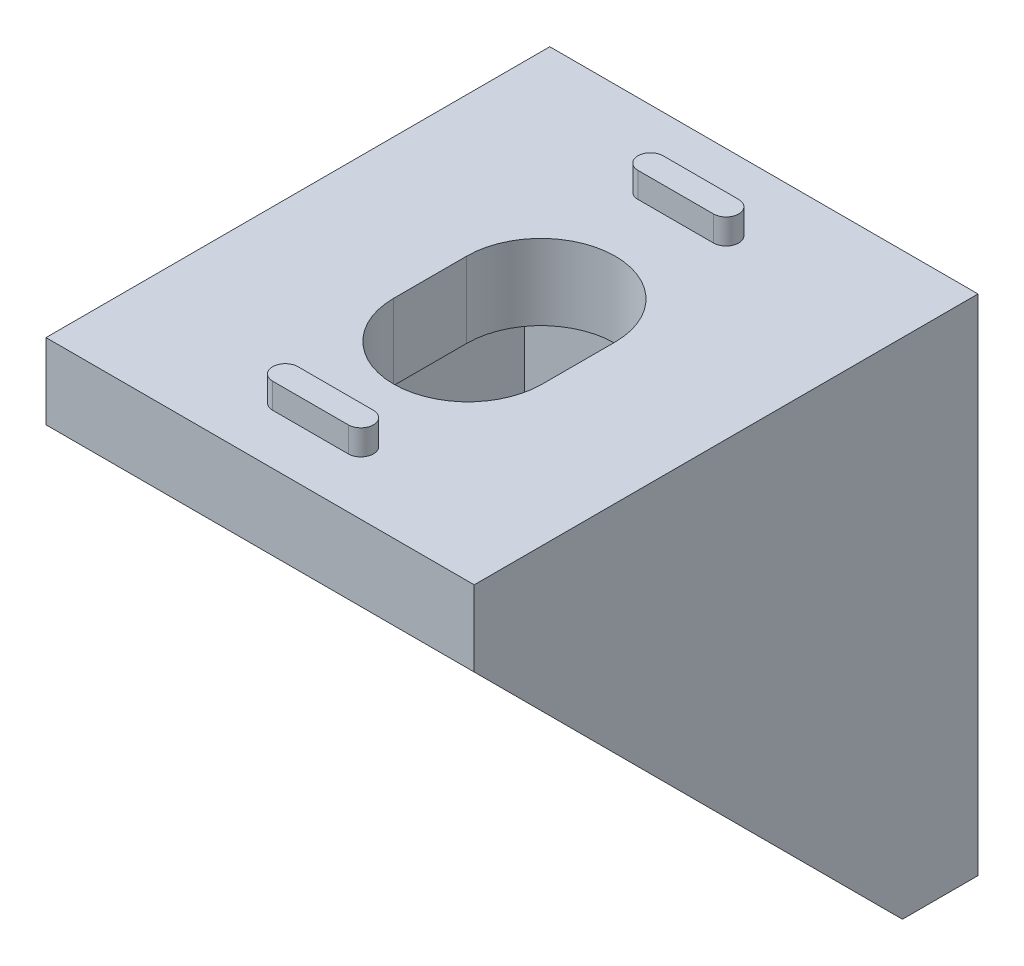
from build123d import *

# Parameters (mm, degrees)
SKETCH_1_W          = 17
SKETCH_1_H          = 20
EXTRUDE_1_DEPTH     = 3
SKETCH_2_W          = 17
SKETCH_2_H          = 3
EXTRUDE_2_DEPTH     = 17
EXTRUDE_3_DEPTH     = 2
EXTRUDE_4_DEPTH     = 2
EXTRUDE_5_DEPTH     = 1
EXTRUDE_6_DEPTH     = 1
CUT_EXTRUDE_3_DEPTH = 21
CUT_EXTRUDE_4_DEPTH = 21


with BuildPart() as part:
    # 草图1 → 凸台-拉伸1 (new body)
    with BuildSketch(Plane.XY):
        Rectangle(SKETCH_1_W, SKETCH_1_H)
    extrude(amount=EXTRUDE_1_DEPTH)

    # 草图2 → 凸台-拉伸2 (add)
    with BuildSketch(Plane.XY.offset(3)):
        with Locations((0, 8.5)):
            Rectangle(SKETCH_2_W, SKETCH_2_H)
    extrude(amount=EXTRUDE_2_DEPTH)

    # 草图3 → 凸台-拉伸3 (add)
    with BuildSketch(Plane.ZY.offset(8.5)):
        Polygon((20, 7), (3, -10), (3, 7), align=None)
    extrude(amount=-EXTRUDE_3_DEPTH)

    # 草图4 → 凸台-拉伸4 (add)
    with BuildSketch(Plane(origin=(8.5, 0, 0), x_dir=(0, 0, -1), z_dir=(1, 0, 0))):
        Polygon((-20, 7), (-3, -10), (-3, 7), align=None)
    extrude(amount=-EXTRUDE_4_DEPTH)

    # 草图5 → 凸台-拉伸5 (add)
    with BuildSketch(Plane(origin=(0, 10, 0), x_dir=(1, 0, 0), z_dir=(0, 1, 0))):
        with BuildLine():
            Line((-1.5, -2.5), (1.5, -2.5))
            ThreePointArc((1.5, -2.5), (2, -3), (1.5, -3.5))
            Line((1.5, -3.5), (-1.5, -3.5))
            ThreePointArc((-1.5, -3.5), (-2, -3), (-1.5, -2.5))
        make_face()
        with BuildLine():
            Line((-1.5, -17), (1.5, -17))
            ThreePointArc((1.5, -17), (2, -17.5), (1.5, -18))
            Line((1.5, -18), (-1.5, -18))
            ThreePointArc((-1.5, -18), (-2, -17.5), (-1.5, -17))
        make_face()
    extrude(amount=EXTRUDE_5_DEPTH)

    # 草图6 → 凸台-拉伸6 (add)
    with BuildSketch(Plane(origin=(0, 0, 0), x_dir=(-1, 0, 0), z_dir=(0, 0, -1))):
        with BuildLine():
            Line((-1.5, 7.5), (1.5, 7.5))
            ThreePointArc((1.5, 7.5), (2, 7), (1.5, 6.5))
            Line((1.5, 6.5), (-1.5, 6.5))
            ThreePointArc((-1.5, 6.5), (-2, 7), (-1.5, 7.5))
        make_face()
        with BuildLine():
            Line((-1.5, -7), (1.5, -7))
            ThreePointArc((1.5, -7), (2, -7.5), (1.5, -8))
            Line((1.5, -8), (-1.5, -8))
            ThreePointArc((-1.5, -8), (-2, -7.5), (-1.5, -7))
        make_face()
    extrude(amount=EXTRUDE_6_DEPTH)

    # 草图7 → 切除-拉伸3 (cut, through all)
    with BuildSketch(Plane(origin=(0, 0, 0), x_dir=(-1, 0, 0), z_dir=(0, 0, -1))):
        with BuildLine():
            Line((2.95, 1.15), (2.95, -1.75))
            ThreePointArc((2.95, -1.75), (0, -4.7), (-2.95, -1.75))
            Line((-2.95, -1.75), (-2.95, 1.15))
            ThreePointArc((-2.95, 1.15), (0, 4.1), (2.95, 1.15))
        make_face()
    extrude(amount=-CUT_EXTRUDE_3_DEPTH, mode=Mode.SUBTRACT)

    # 草图8 → 切除-拉伸4 (cut, through all)
    with BuildSketch(Plane(origin=(0, 10, 0), x_dir=(1, 0, 0), z_dir=(0, 1, 0))):
        with BuildLine():
            Line((2.95, -8.85), (2.95, -11.75))
            ThreePointArc((2.95, -11.75), (0, -14.7), (-2.95, -11.75))
            Line((-2.95, -11.75), (-2.95, -8.85))
            ThreePointArc((-2.95, -8.85), (0, -5.9), (2.95, -8.85))
        make_face()
    extrude(amount=-CUT_EXTRUDE_4_DEPTH, mode=Mode.SUBTRACT)


solid = part.part
